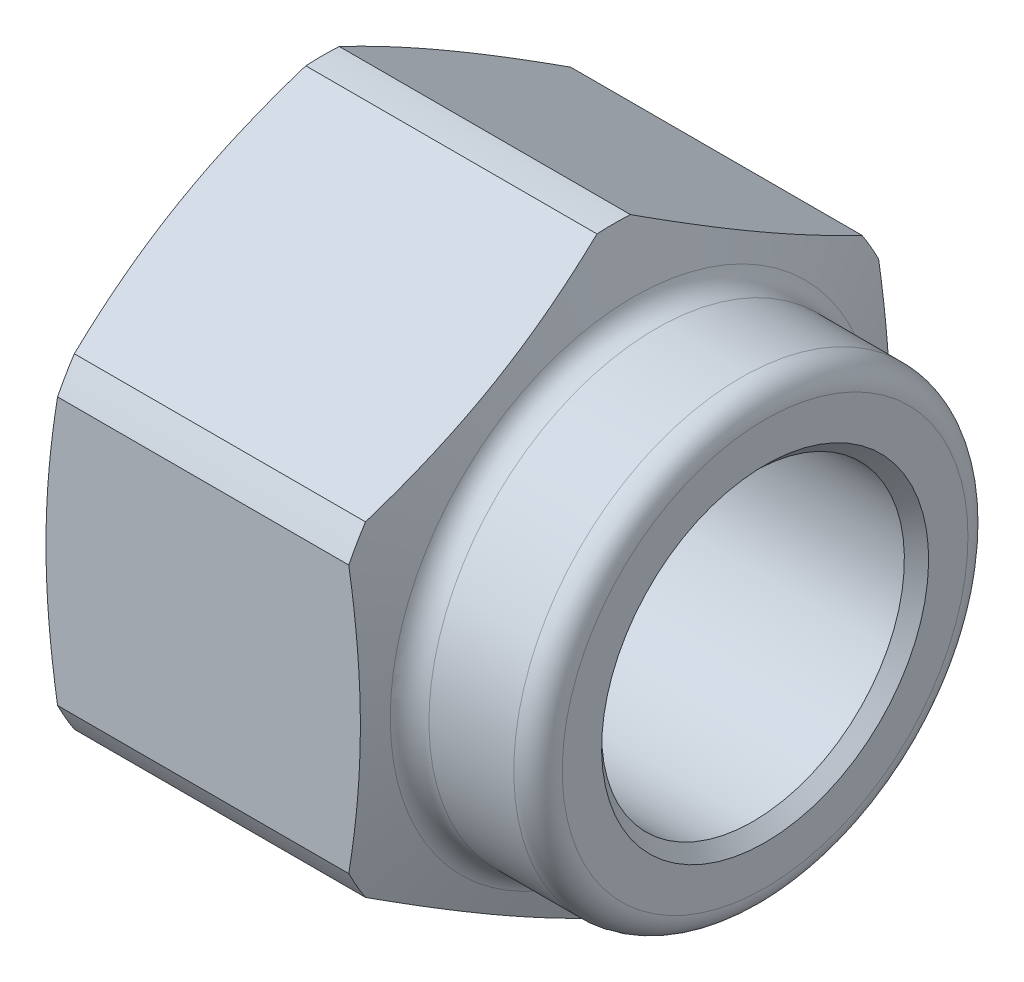
from build123d import *

# Parameters (mm, degrees)
BOSS_EXTRUDE1_DEPTH = 9.525
FILLET1_R           = 0.508


with BuildPart() as part:
    # Sketch1 → Boss-Extrude1 (new body)
    with BuildSketch(Plane(origin=(0, 0, 0), x_dir=(0, 0, -1), z_dir=(1, 0, 0))):
        Polygon((0, 6.415804866), (-5.55625, 3.207902433), (-5.55625, -3.207902433), (0, -6.415804866), (5.55625, -3.207902433), (5.55625, 3.207902433), align=None)
    extrude(amount=BOSS_EXTRUDE1_DEPTH)

    # Sketch2 → Cut-Revolve2 (revolve, cut)
    with BuildSketch(Plane.XY):
        Polygon((0, 0), (9.525, 0), (9.525, 3.429), (9.271, 3.175), (0.254, 3.175), (0, 3.429), align=None)
        Polygon((0, 5.55625), (0.242677154, 6.223), (6.35, 6.223), (6.881578527, 4.7625), (9.525, 4.7625), (9.525, 6.415804866), (0, 6.415804866), align=None)
    revolve(axis=Axis((0, 0, 0), (1, 0, 0)), mode=Mode.SUBTRACT)

    # Fillet1
    fillet1_edges = [part.edges().sort_by_distance(p)[0] for p in [
        (9.525, -4.7625, 0),
        (6.881578527, -4.7625, 0),
    ]]
    fillet(fillet1_edges, radius=FILLET1_R)


solid = part.part
